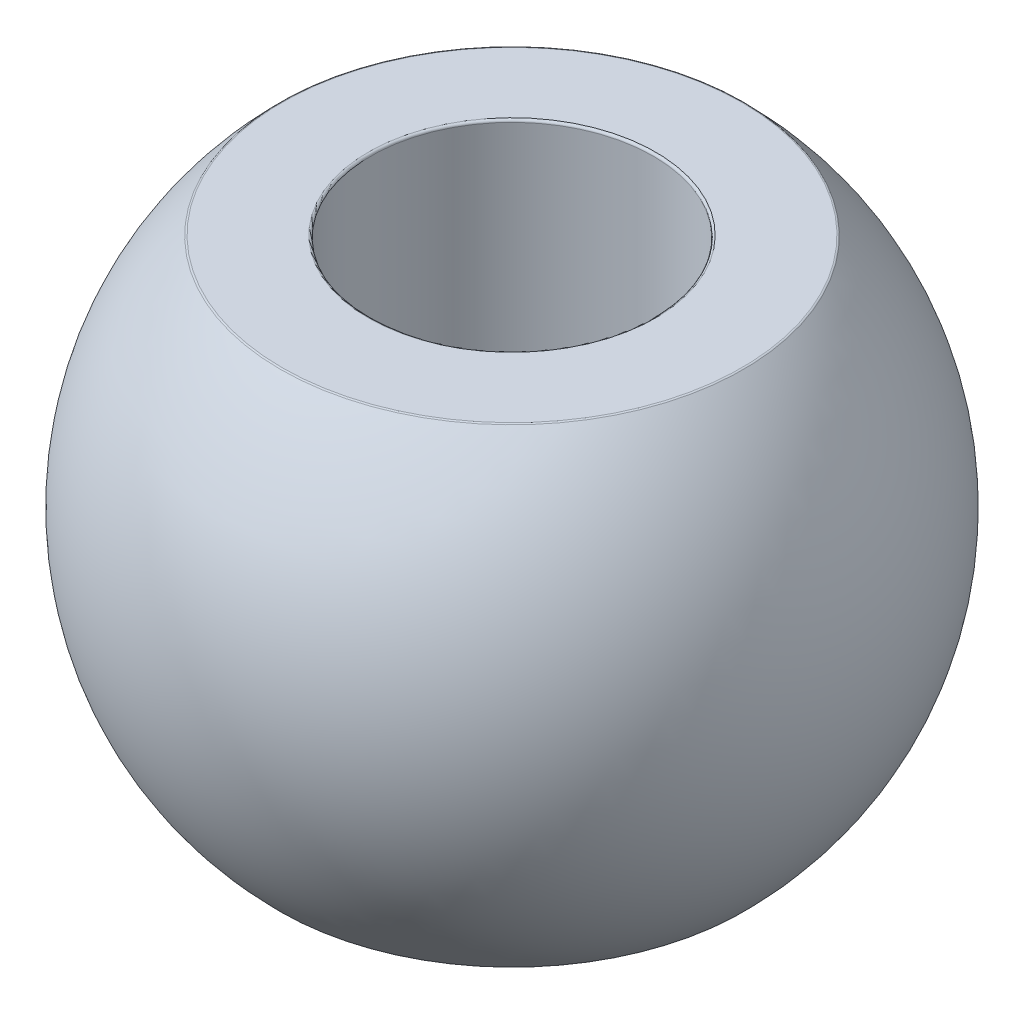
from build123d import *

# Parameters (mm, degrees)
FILLET1_R = 0.1


with BuildPart() as part:
    # Sketch1 → Revolve1 (revolve)
    with BuildSketch(Plane.XY):
        with BuildLine():
            Line((6, -10), (6, 10))
            Line((6, 10), (9.797958971, 10))
            ThreePointArc((9.797958971, 10), (14, 0), (9.797958971, -10))
            Line((9.797958971, -10), (6, -10))
        make_face()
    revolve(axis=Axis((0, 0, 0), (0, 1, 0)))

    # Fillet1
    fillet1_edges = [part.edges().sort_by_distance(p)[0] for p in [
        (-9.797958971, -10, 0),
        (-9.797958971, 10, 0),
        (-6, 10, 0),
        (-6, -10, 0),
    ]]
    fillet(fillet1_edges, radius=FILLET1_R)


solid = part.part
